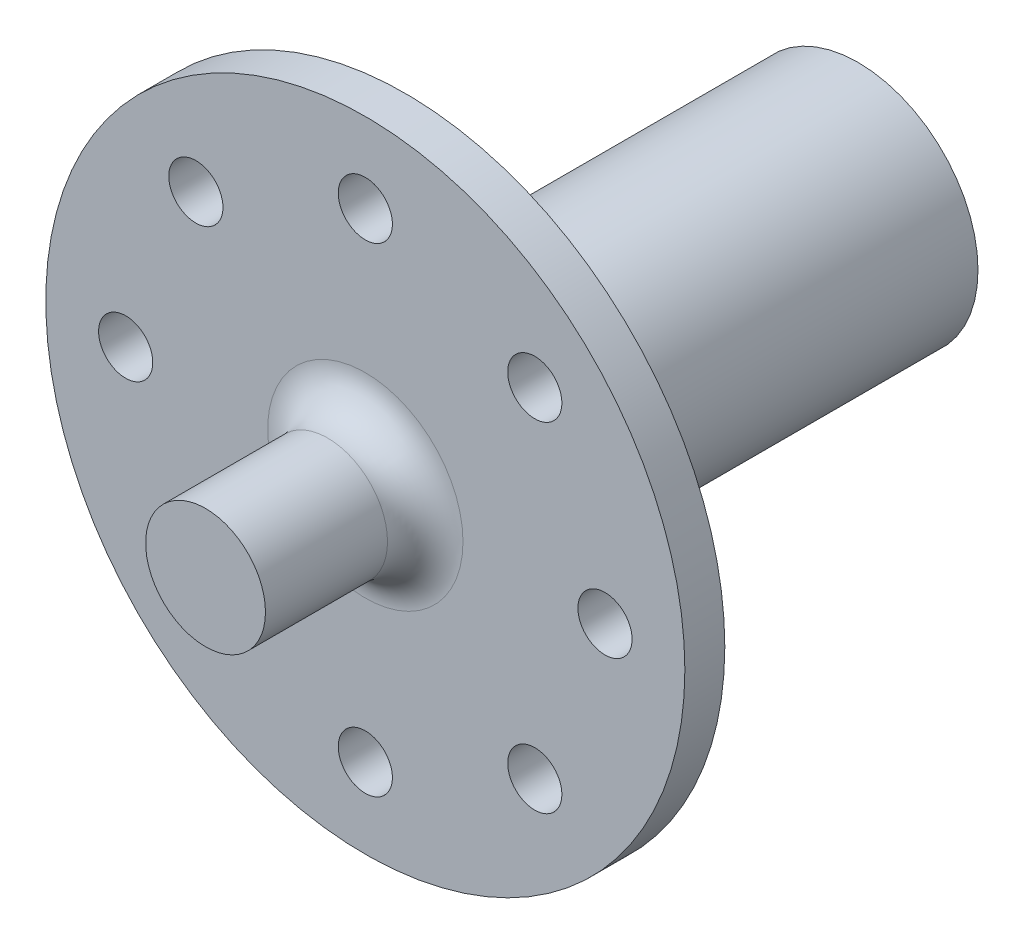
from build123d import *

# Parameters (mm, degrees)
SKETCH1_R           = 9.525
BOSS_EXTRUDE1_DEPTH = 36
SKETCH2_R           = 25.4
BOSS_EXTRUDE2_DEPTH = 3.175
SKETCH3_R           = 4.7625
BOSS_EXTRUDE3_DEPTH = 12.7
SKETCH4_R           = 2.15265
CUT_EXTRUDE1_DEPTH  = 19.05
FILLET1_R           = 3
SKETCH5_W           = 3
SKETCH5_H           = 1.491900756
BOSS_EXTRUDE4_DEPTH = 10.6


with BuildPart() as part:
    # Sketch1 → Boss-Extrude1 (new body)
    with BuildSketch(Plane.XY):
        Circle(SKETCH1_R)
        with BuildLine():
            Line((-1.5, 5.2), (1.5, 5.2))
            Line((1.5, 5.2), (1.5, 3.708099244))
            ThreePointArc((1.5, 3.708099244), (0, -4), (-1.5, 3.708099244))
            Line((-1.5, 3.708099244), (-1.5, 5.2))
        make_face(mode=Mode.SUBTRACT)
    extrude(amount=BOSS_EXTRUDE1_DEPTH)

    # Sketch2 → Boss-Extrude2 (add)
    with BuildSketch(Plane.XY.offset(36)):
        Circle(SKETCH2_R)
    extrude(amount=BOSS_EXTRUDE2_DEPTH)

    # Sketch3 → Boss-Extrude3 (add)
    with BuildSketch(Plane.XY.offset(39.175)):
        Circle(SKETCH3_R)
    extrude(amount=BOSS_EXTRUDE3_DEPTH)

    # Sketch4 → Cut-Extrude1 (cut)
    with BuildSketch(Plane.XY.offset(39.175)):
        with Locations((0, 19.05)):
            Circle(SKETCH4_R)
        with Locations((13.470384182, 13.470384182)):
            Circle(SKETCH4_R)
        with Locations((19.05, 0)):
            Circle(SKETCH4_R)
        with Locations((13.470384182, -13.470384182)):
            Circle(SKETCH4_R)
        with Locations((-19.05, 0)):
            Circle(SKETCH4_R)
        with Locations((0, -19.05)):
            Circle(SKETCH4_R)
        with Locations((-13.470384182, -13.470384182)):
            Circle(SKETCH4_R)
        with Locations((-13.470384182, 13.470384182)):
            Circle(SKETCH4_R)
    extrude(amount=-CUT_EXTRUDE1_DEPTH, mode=Mode.SUBTRACT)

    # Fillet1
    fillet1_edges = [part.edges().sort_by_distance(p)[0] for p in [
        (-4.7625, 0, 39.175),
    ]]
    fillet(fillet1_edges, radius=FILLET1_R)

    # Sketch5 → Boss-Extrude4 (add)
    with BuildSketch(Plane(origin=(0, 0, 36), x_dir=(-1, 0, 0), z_dir=(0, 0, -1))):
        with Locations((0, 4.454049622)):
            Rectangle(SKETCH5_W, SKETCH5_H)
    extrude(amount=BOSS_EXTRUDE4_DEPTH)


solid = part.part
